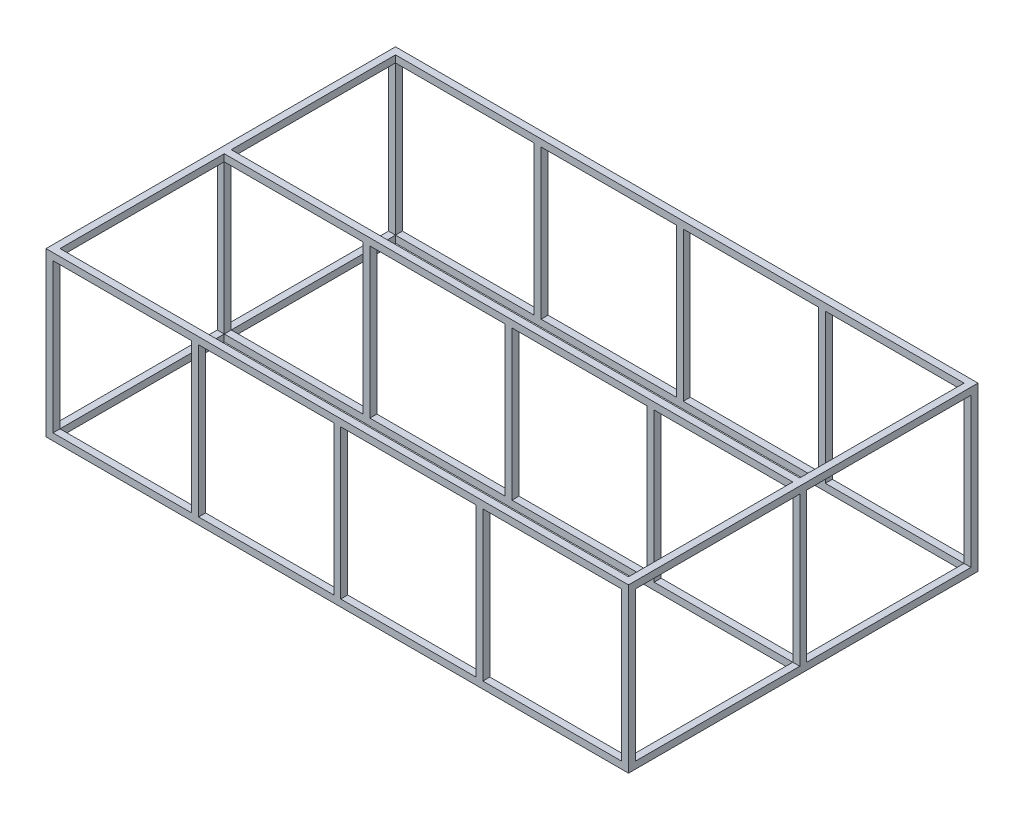
from build123d import *

# Parameters (mm, degrees)
SKETCH1_W           = 2500
SKETCH1_H           = 700
SKETCH1_W_2         = 2440
SKETCH1_H_2         = 640
BOSS_EXTRUDE1_DEPTH = 1500
SKETCH2_W           = 2440
SKETCH2_H           = 1440
CUT_EXTRUDE1_DEPTH  = 1500
SKETCH3_W           = 1440
SKETCH3_H           = 640
CUT_EXTRUDE2_DEPTH  = 3595
SKETCH5_W           = 15
SKETCH5_H           = 30
BOSS_EXTRUDE3_DEPTH = 640
BOSS_EXTRUDE4_REACH = 2472
SKETCH7_W           = 30
SKETCH7_H           = 30
SKETCH8_W           = 30
SKETCH8_H           = 30
BOSS_EXTRUDE5_DEPTH = 640


with BuildPart() as part:
    # Sketch1 → Boss-Extrude1 (new body)
    with BuildSketch(Plane.XY):
        with Locations((1250, 350)):
            Rectangle(SKETCH1_W, SKETCH1_H)
        with Locations((1250, 350)):
            Rectangle(SKETCH1_W_2, SKETCH1_H_2, mode=Mode.SUBTRACT)
    extrude(amount=BOSS_EXTRUDE1_DEPTH)

    # Sketch2 → Cut-Extrude1 (cut)
    with BuildSketch(Plane(origin=(0, 700, 0), x_dir=(1, 0, 0), z_dir=(0, 1, 0))):
        with Locations((1250, -750)):
            Rectangle(SKETCH2_W, SKETCH2_H)
    extrude(amount=-CUT_EXTRUDE1_DEPTH, mode=Mode.SUBTRACT)

    # Sketch3 → Cut-Extrude2 (cut)
    with BuildSketch(Plane(origin=(2500, 0, 0), x_dir=(0, 0, -1), z_dir=(1, 0, 0))):
        with Locations((-750, 350)):
            Rectangle(SKETCH3_W, SKETCH3_H)
    extrude(amount=-CUT_EXTRUDE2_DEPTH, mode=Mode.SUBTRACT)

    # Sketch5 → Boss-Extrude3 (add)
    with BuildSketch(Plane(origin=(0, 30, 0), x_dir=(1, 0, 0), z_dir=(0, 1, 0))):
        with Locations((632.5, -15)):
            Rectangle(SKETCH5_W, SKETCH5_H)
        with Locations((647.5, -15)):
            Rectangle(SKETCH5_W, SKETCH5_H)
        with Locations((1242.5, -15)):
            Rectangle(SKETCH5_W, SKETCH5_H)
        with Locations((1257.5, -15)):
            Rectangle(SKETCH5_W, SKETCH5_H)
        Polygon((1860, 0), (1845, 0), (1845, -30), (1860, -30), (1875, -30), (1875, 0), align=None)
        with Locations((1852.5, -1485)):
            Rectangle(SKETCH5_W, SKETCH5_H)
        with Locations((1867.5, -1485)):
            Rectangle(SKETCH5_W, SKETCH5_H)
        with Locations((1242.5, -1485)):
            Rectangle(SKETCH5_W, SKETCH5_H)
        with Locations((1257.5, -1485)):
            Rectangle(SKETCH5_W, SKETCH5_H)
        with Locations((647.5, -1485)):
            Rectangle(SKETCH5_W, SKETCH5_H)
        with Locations((632.5, -1485)):
            Rectangle(SKETCH5_W, SKETCH5_H)
    extrude(amount=BOSS_EXTRUDE3_DEPTH)

    # Sketch7 → Boss-Extrude4 (add, up to next)
    with BuildSketch(Plane(origin=(30, 0, 0), x_dir=(0, 0, -1), z_dir=(1, 0, 0)), mode=Mode.PRIVATE) as boss_extrude4_sk1:
        with Locations((-750, 15)):
            Rectangle(SKETCH7_W, SKETCH7_H)
    boss_extrude4_tool1 = extrude(boss_extrude4_sk1.sketch, amount=BOSS_EXTRUDE4_REACH, mode=Mode.PRIVATE) - part.part
    add(boss_extrude4_tool1.solids().sort_by_distance((30, 15, 750))[0])
    # Sketch7 → Boss-Extrude4 (add, up to next)
    with BuildSketch(Plane(origin=(30, 0, 0), x_dir=(0, 0, -1), z_dir=(1, 0, 0)), mode=Mode.PRIVATE) as boss_extrude4_sk2:
        with Locations((-750, 685)):
            Rectangle(SKETCH7_W, SKETCH7_H)
    boss_extrude4_tool2 = extrude(boss_extrude4_sk2.sketch, amount=BOSS_EXTRUDE4_REACH, mode=Mode.PRIVATE) - part.part
    add(boss_extrude4_tool2.solids().sort_by_distance((30, 685, 750))[0])

    # Sketch8 → Boss-Extrude5 (add)
    with BuildSketch(Plane(origin=(0, 30, 0), x_dir=(1, 0, 0), z_dir=(0, 1, 0))):
        with Locations((2485, -750)):
            Rectangle(SKETCH8_W, SKETCH8_H)
        with Locations((15, -750)):
            Rectangle(SKETCH8_W, SKETCH8_H)
        with Locations((640, -750)):
            Rectangle(SKETCH8_W, SKETCH8_H)
        with Locations((1250, -750)):
            Rectangle(SKETCH8_W, SKETCH8_H)
        with Locations((1860, -750)):
            Rectangle(SKETCH8_W, SKETCH8_H)
    extrude(amount=BOSS_EXTRUDE5_DEPTH)


solid = part.part
